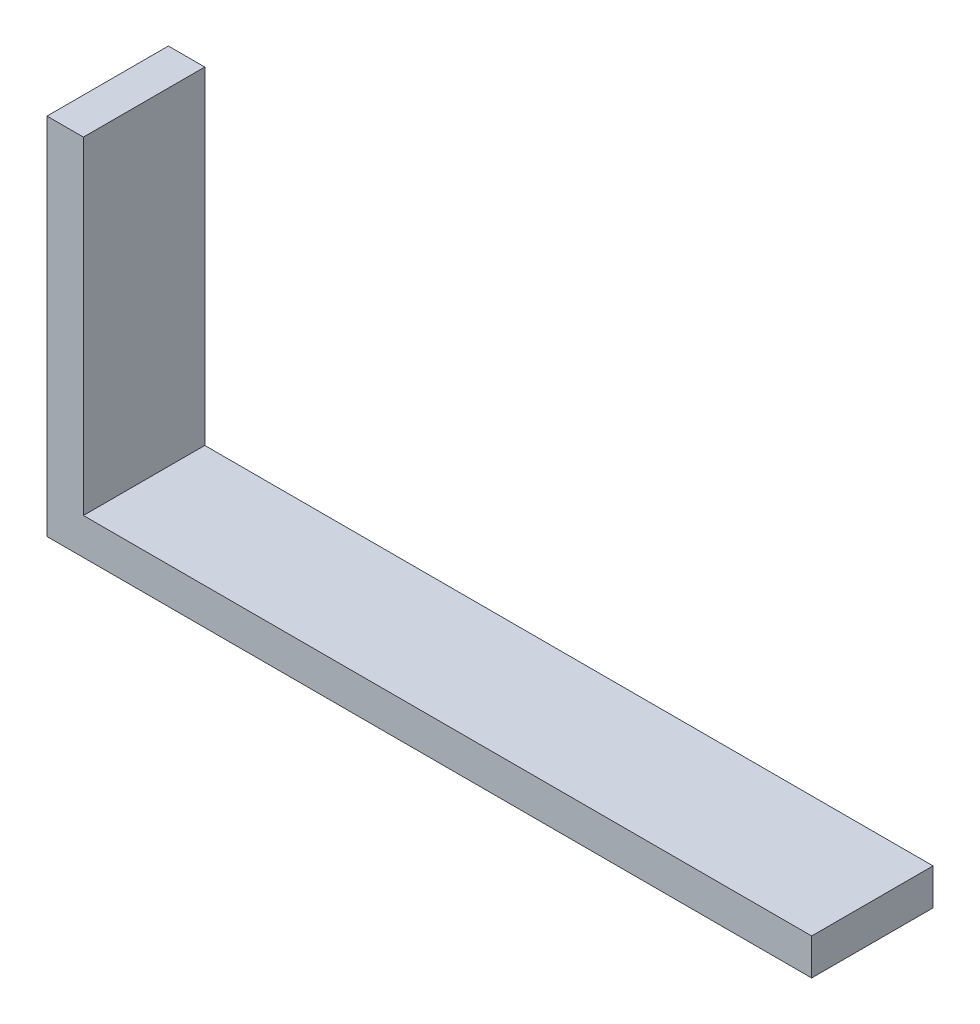
from build123d import *

# Parameters (mm, degrees)
BOSS_EXTRUDE1_DEPTH = 10


with BuildPart() as part:
    # Sketch1 → Boss-Extrude1 (new body)
    with BuildSketch(Plane.XY):
        Polygon((0, 0), (0, 30), (3, 30), (3, 3), (63, 3), (63, 0), align=None)
    extrude(amount=BOSS_EXTRUDE1_DEPTH)


solid = part.part
